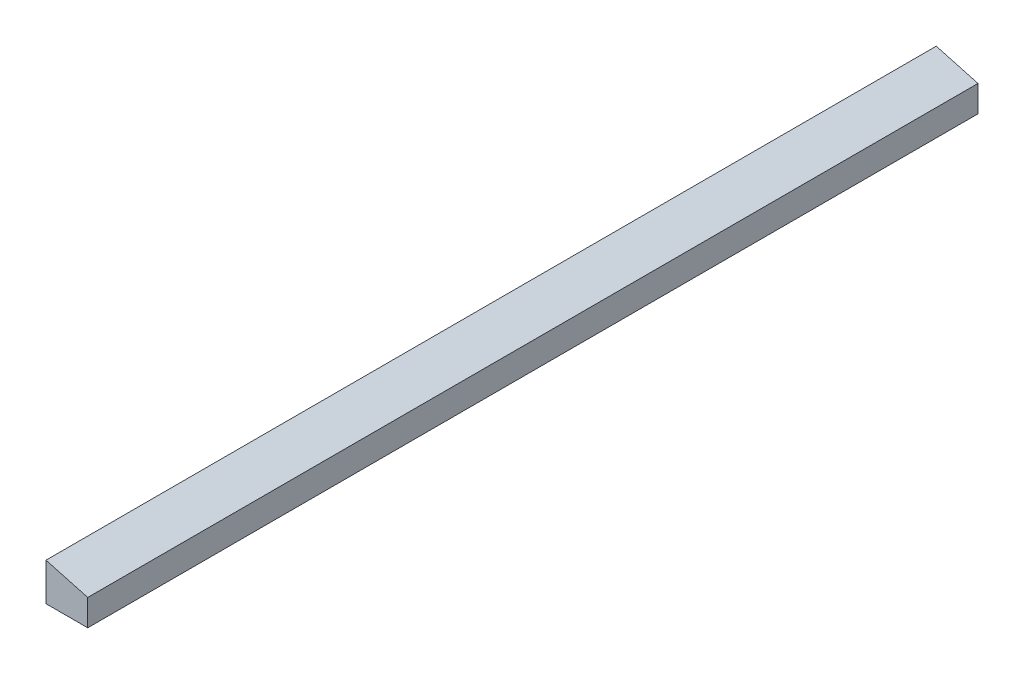
from build123d import *

# Parameters (mm, degrees)
BOSS_EXTRUDE1_DEPTH = 304.8


with BuildPart() as part:
    # Sketch1 → Boss-Extrude1 (new body, symmetric)
    with BuildSketch(Plane.XY):
        Polygon((0, 32.200120786), (0, 6.35), (28.575, 6.35), (28.575, 24.38288538), align=None)
    extrude(amount=BOSS_EXTRUDE1_DEPTH, both=True)


solid = part.part
